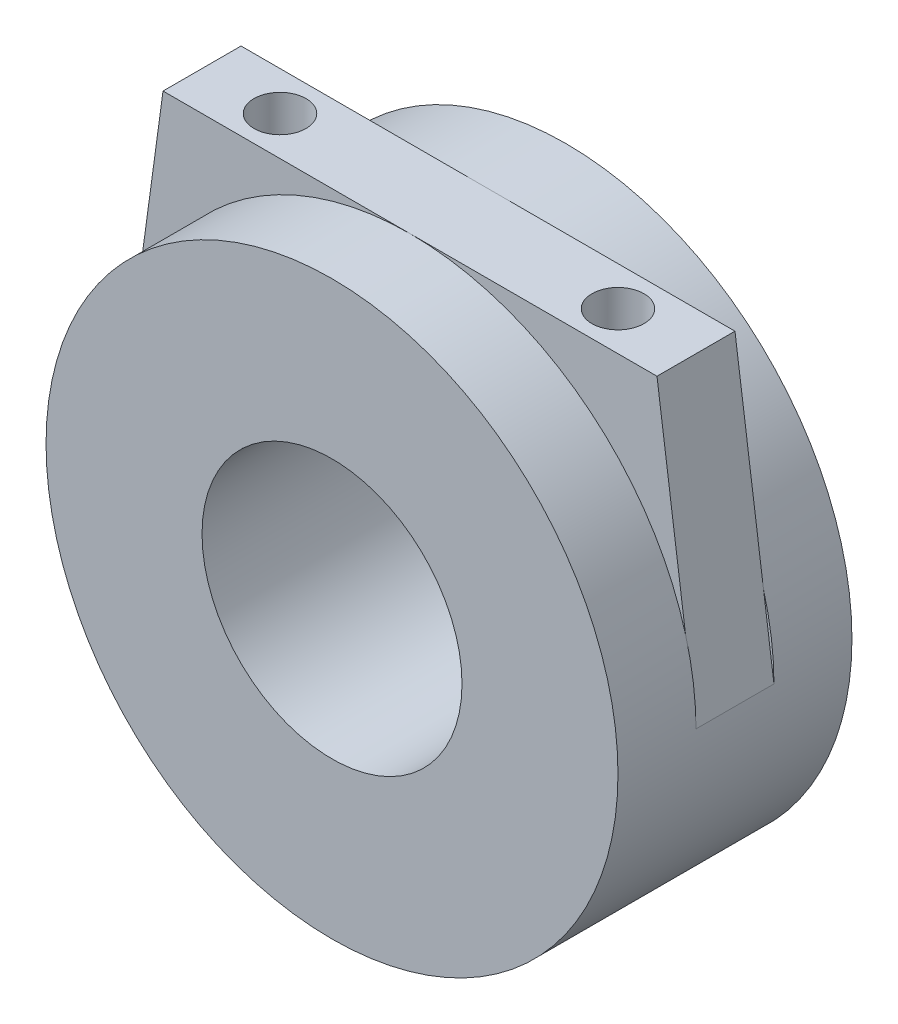
from build123d import *

# Parameters (mm, degrees)
SKETCH1_R           = 11
BOSS_EXTRUDE1_DEPTH = 3
BOSS_EXTRUDE2_DEPTH = 3
SKETCH3_R           = 11
BOSS_EXTRUDE3_DEPTH = 3
SKETCH4_R           = 5
CUT_EXTRUDE1_DEPTH  = 10
SKETCH5_R           = 1
CUT_EXTRUDE2_DEPTH  = 3


with BuildPart() as part:
    # Sketch1 → Boss-Extrude1 (new body)
    with BuildSketch(Plane.XY):
        Circle(SKETCH1_R)
    extrude(amount=BOSS_EXTRUDE1_DEPTH)

    # Sketch2 → Boss-Extrude2 (add)
    with BuildSketch(Plane.XY.offset(3)):
        with BuildLine():
            Line((-11, 0), (-9.5, 11))
            Line((-9.5, 11), (9.5, 11))
            Line((9.5, 11), (11, 0))
            ThreePointArc((11, 0), (0, -11), (-11, 0))
        make_face()
    extrude(amount=BOSS_EXTRUDE2_DEPTH)

    # Sketch3 → Boss-Extrude3 (add)
    with BuildSketch(Plane.XY.offset(6)):
        Circle(SKETCH3_R)
    extrude(amount=BOSS_EXTRUDE3_DEPTH)

    # Sketch4 → Cut-Extrude1 (cut, through all)
    with BuildSketch(Plane.XY.offset(9)):
        Circle(SKETCH4_R)
    extrude(amount=-CUT_EXTRUDE1_DEPTH, mode=Mode.SUBTRACT)

    # Sketch5 → Cut-Extrude2 (cut)
    with BuildSketch(Plane(origin=(0, 11, 0), x_dir=(1, 0, 0), z_dir=(0, 1, 0))):
        with Locations((-6.5, -4.5)):
            Circle(SKETCH5_R)
        with Locations((6.5, -4.5)):
            Circle(SKETCH5_R)
    extrude(amount=-CUT_EXTRUDE2_DEPTH, mode=Mode.SUBTRACT)


solid = part.part
